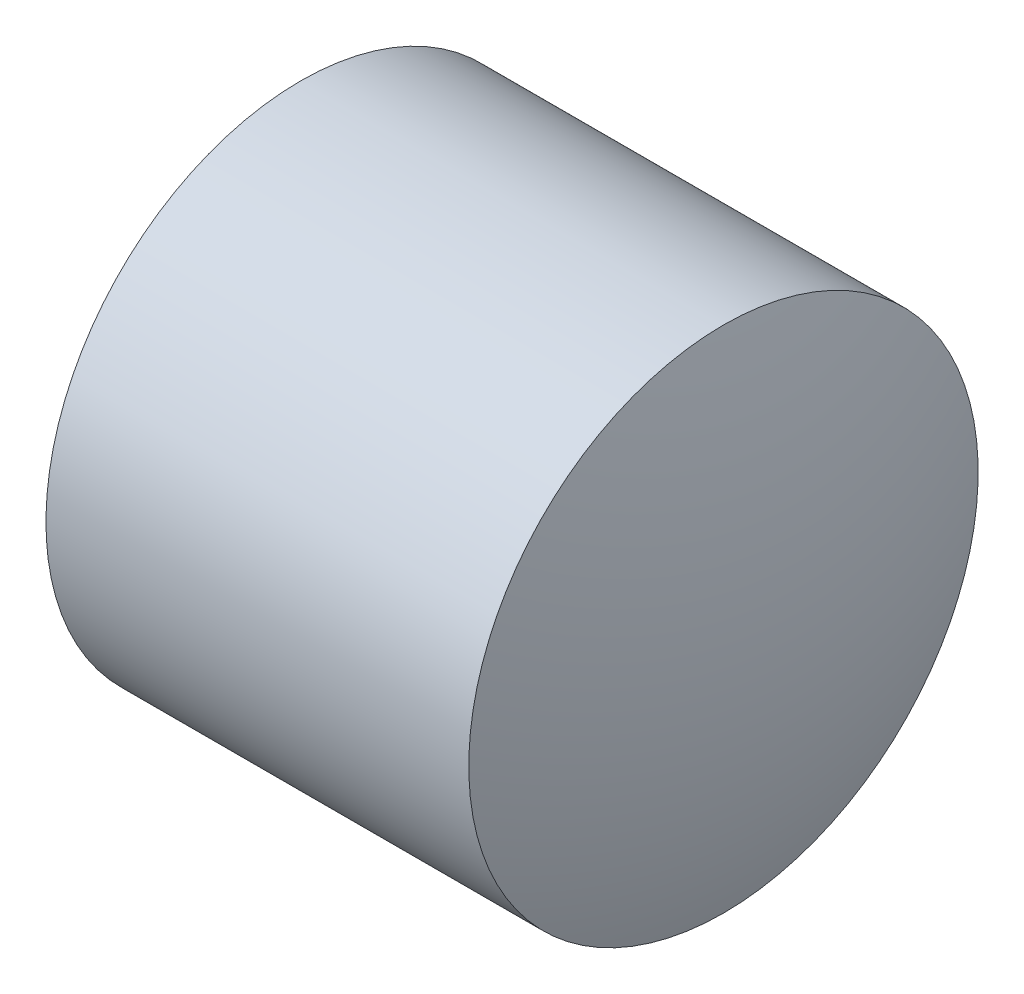
from build123d import *


with BuildPart() as part:
    # 草图2 one side → 旋转1 (revolve)
    with BuildSketch(Plane.XY, mode=Mode.PRIVATE) as revolve_1_sk:
        with BuildLine():
            Line((23.423194871, 11.48412514), (17.423209949, 11.48412514))
            ThreePointArc((17.423209949, 11.48412514), (17.551616136, 9.962604642), (17.93320241, 8.484124107))
            Line((17.93320241, 8.484124107), (22.91320241, 8.484124107))
            ThreePointArc((22.91320241, 8.484124107), (23.294788685, 9.962604642), (23.423194871, 11.48412514))
        make_face()
    revolve(revolve_1_sk.sketch.rotate(Axis((23.77530363, 11.48412514, 0), (-1, 0, 0)), 180), axis=Axis((23.77530363, 11.48412514, 0), (-1, 0, 0)))  # turned: the seam where the file's is


solid = part.part
